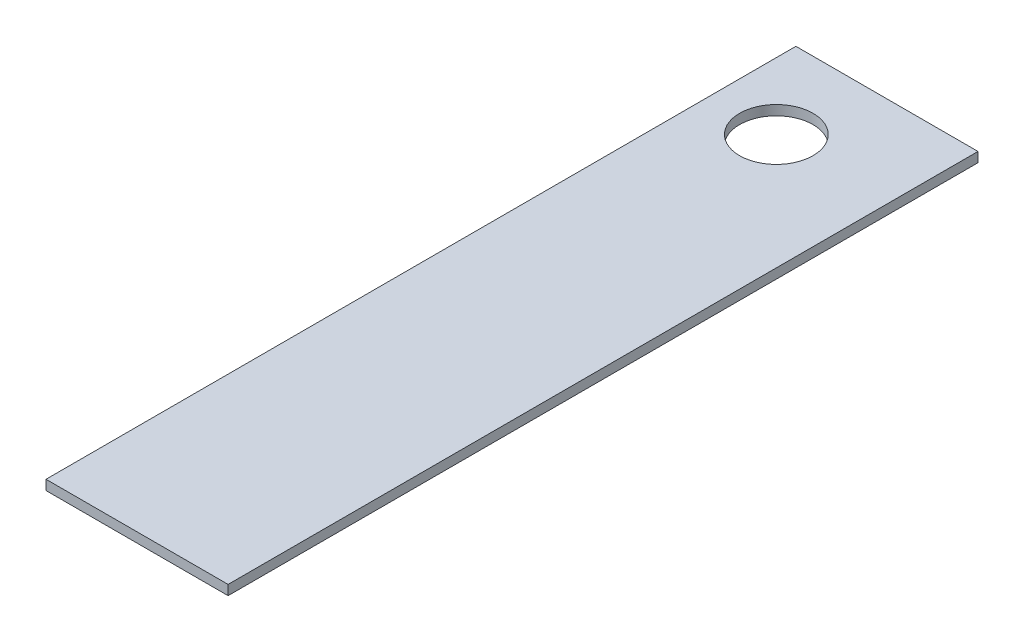
from build123d import *

# Parameters (mm, degrees)
SKETCH2_W           = 18.6
SKETCH2_H           = 76.6
SKETCH2_R           = 3.75
BOSS_EXTRUDE1_DEPTH = 1


with BuildPart() as part:
    # Sketch2 → Boss-Extrude1 (new body)
    with BuildSketch(Plane(origin=(0, 0, 0), x_dir=(1, 0, 0), z_dir=(0, 1, 0))):
        with Locations((-31.729014151, 24.017653569)):
            Rectangle(SKETCH2_W, SKETCH2_H)
        with Locations((-34.229014151, 53.517653569)):
            Circle(SKETCH2_R, mode=Mode.SUBTRACT)
    extrude(amount=BOSS_EXTRUDE1_DEPTH)


solid = part.part
